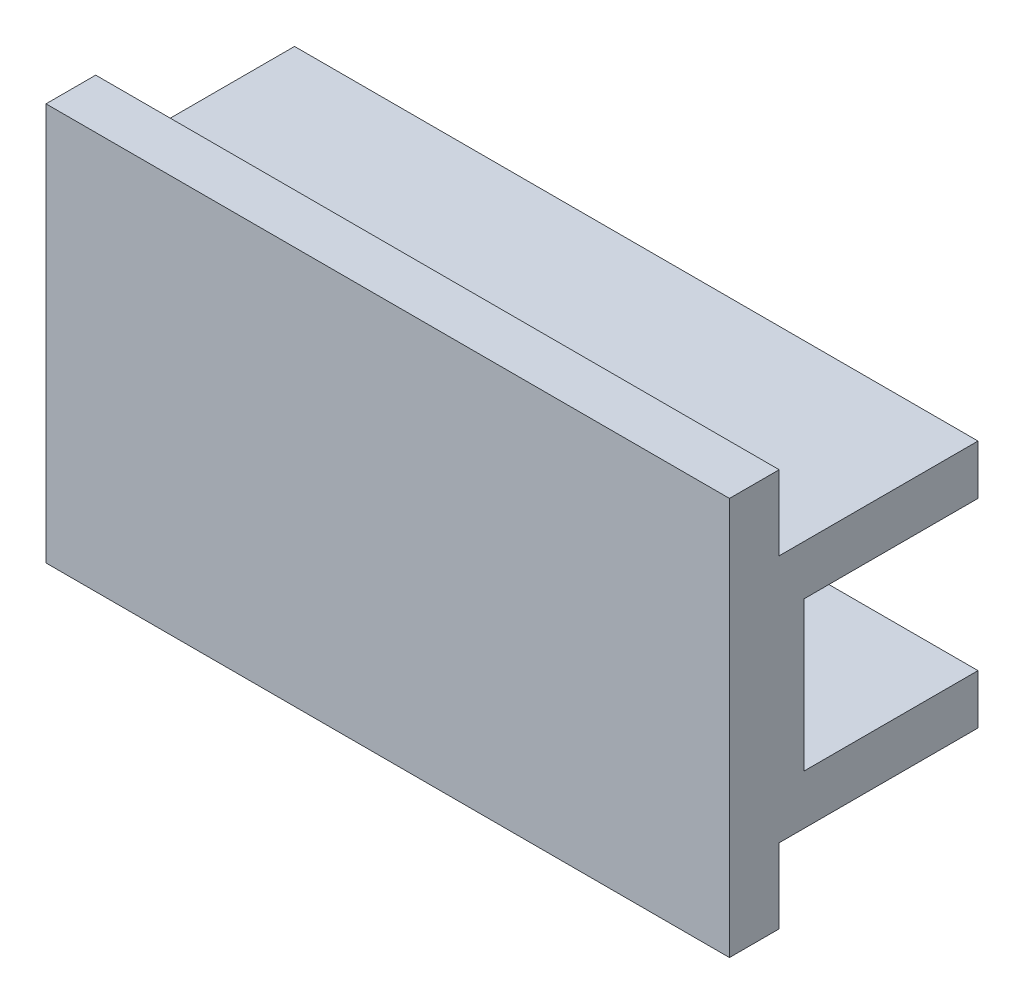
from build123d import *

# Parameters (mm, degrees)
EXTRUDE1_DEPTH = 13.75
SKETCH2_W      = 1
SKETCH2_H      = 6
EXTRUDE2_DEPTH = 21.5
EXTRUDE3_DEPTH = 1


with BuildPart() as part:
    # Sketch1 → Extrude1 (new body, symmetric)
    with BuildSketch(Plane(origin=(0, 0, 0), x_dir=(0, 0, -1), z_dir=(1, 0, 0))):
        Polygon((-3, 8), (-3, 5), (5, 5), (5, 3), (-2, 3), (-2, -3), (5, -3), (5, -5), (-3, -5), (-3, -8), (-5, -8), (-5, 8), align=None)
    extrude(amount=EXTRUDE1_DEPTH, both=True)

    # Sketch2 → Extrude2 (cut)
    with BuildSketch(Plane.ZY.offset(13.75)):
        with Locations((2.5, 0)):
            Rectangle(SKETCH2_W, SKETCH2_H)
    extrude(amount=-EXTRUDE2_DEPTH, mode=Mode.SUBTRACT)

    # Sketch3 → Extrude3 (cut)
    with BuildSketch(Plane(origin=(0, 0, 2), x_dir=(-1, 0, 0), z_dir=(0, 0, -1))):
        with BuildLine():
            Line((-7.75, 3), (-7.75, -3))
            ThreePointArc((-7.75, -3), (-10.75, 0), (-7.75, 3))
        make_face()
    extrude(amount=-EXTRUDE3_DEPTH, mode=Mode.SUBTRACT)


solid = part.part
